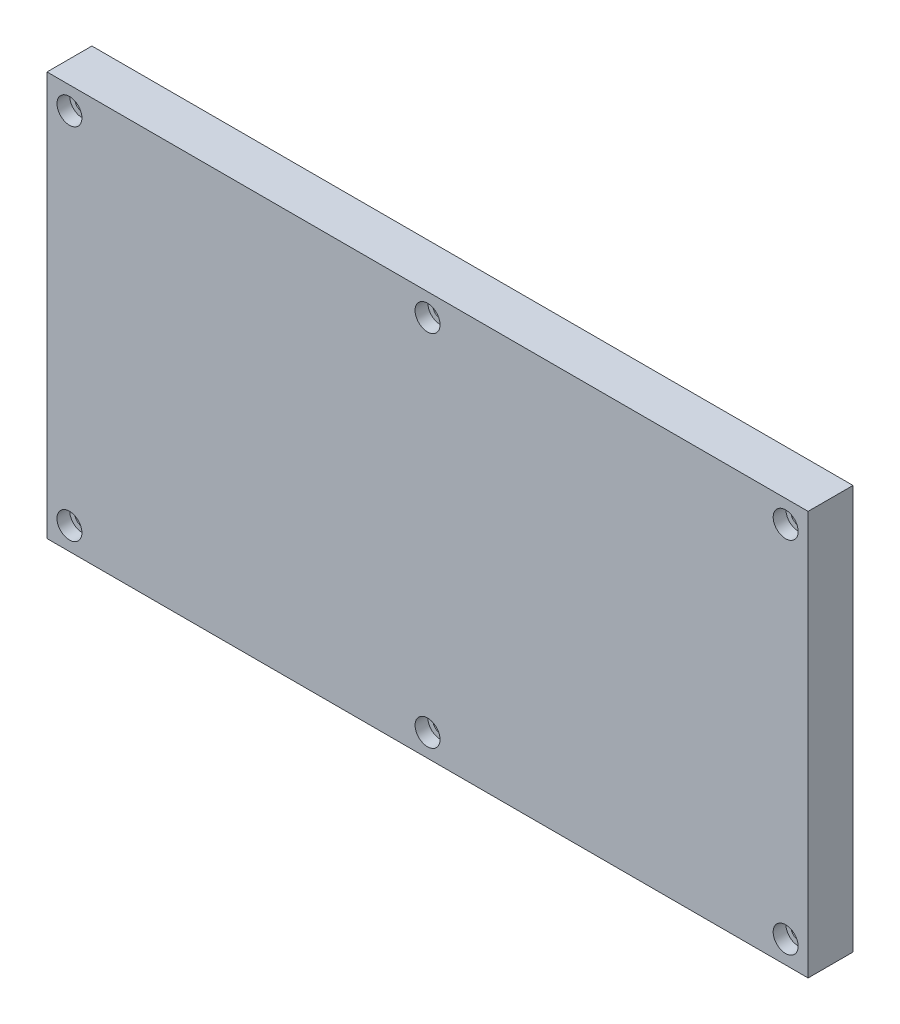
from build123d import *

# Parameters (mm, degrees)
SKETCH1_W                                      = 169.5
SKETCH1_H                                      = 90
BOSS_EXTRUDE1_DEPTH                            = 10
CBORE_FOR_4_SOCKET_HEAD_CAP_SCREW1_D           = 3.2639
CBORE_FOR_4_SOCKET_HEAD_CAP_SCREW1_CBORE_D     = 5.55752
CBORE_FOR_4_SOCKET_HEAD_CAP_SCREW1_CBORE_DEPTH = 2.8448


with BuildPart() as part:
    # Sketch1 → Boss-Extrude1 (new body)
    with BuildSketch(Plane.XY):
        with Locations((84.75, 45)):
            Rectangle(SKETCH1_W, SKETCH1_H)
    extrude(amount=BOSS_EXTRUDE1_DEPTH)

    # CBORE for #4 Socket Head Cap Screw1 (through all)
    with Locations(Plane.XY.offset(10)):
        with Locations((5, 85), (164.5, 85), (164.5, 5), (5, 5), (84.75, 5), (84.75, 85)):
            CounterBoreHole(CBORE_FOR_4_SOCKET_HEAD_CAP_SCREW1_D / 2, CBORE_FOR_4_SOCKET_HEAD_CAP_SCREW1_CBORE_D / 2, CBORE_FOR_4_SOCKET_HEAD_CAP_SCREW1_CBORE_DEPTH)


solid = part.part
